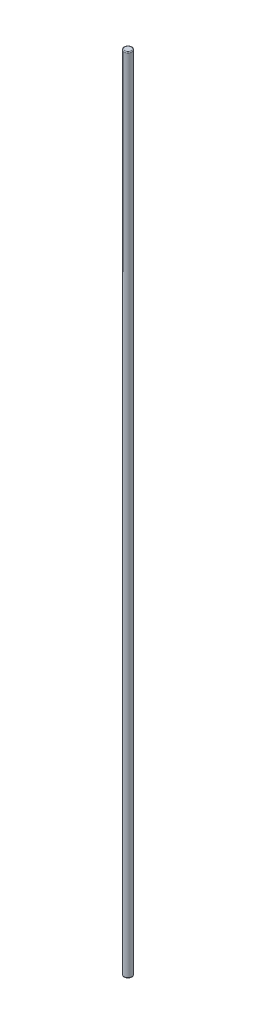
from build123d import *

# Parameters (mm, degrees)
SKETCH1_R           = 1
BOSS_EXTRUDE1_DEPTH = 200
FILLET1_R           = 0.2


with BuildPart() as part:
    # Sketch1 → Boss-Extrude1 (new body)
    with BuildSketch(Plane(origin=(0, 0, 0), x_dir=(1, 0, 0), z_dir=(0, 1, 0))):
        Circle(SKETCH1_R)
    extrude(amount=BOSS_EXTRUDE1_DEPTH)

    # Fillet1
    fillet1_edges = [part.edges().sort_by_distance(p)[0] for p in [
        (-1, 0, 0),
        (-1, 200, 0),
    ]]
    fillet(fillet1_edges, radius=FILLET1_R)


solid = part.part
